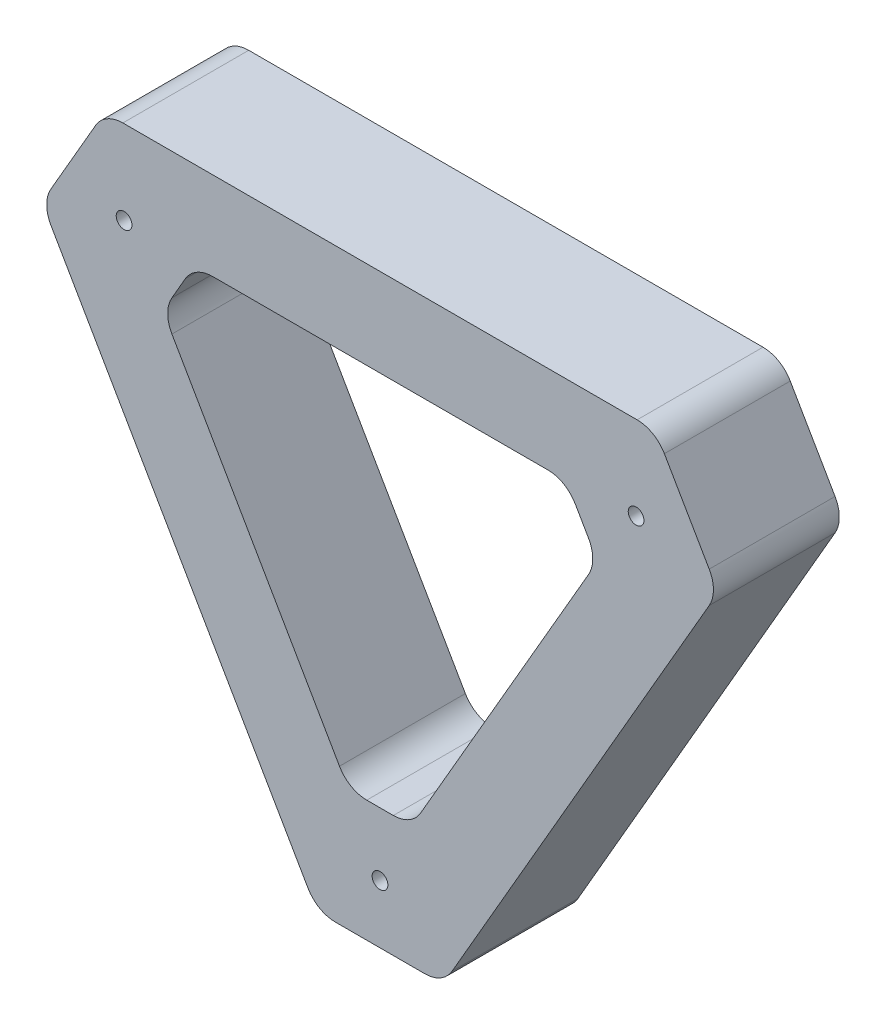
from build123d import *

# Parameters (mm, degrees)
MODEL_R                  = 1.25
RESSALTO_EXTRUS_O1_DEPTH = 20


with BuildPart() as part:
    # Model → Ressalto-extrusão1 (new body)
    with BuildSketch(Plane.XY):
        with BuildLine():
            Line((11.694931393, 184.007671687), (18.798816999, 196.310732401))
            ThreePointArc((18.798816999, 196.310732401), (20.628779754, 198.140639612), (23.128489927, 198.81054493))
            Line((23.128489927, 198.81054493), (104.854461984, 198.816198006))
            ThreePointArc((104.854461984, 198.816198006), (107.353091528, 198.147315496), (109.183125054, 196.319330074))
            Line((109.183125054, 196.319330074), (116.309159239, 183.99727285))
            ThreePointArc((116.309159239, 183.99727285), (116.980841789, 181.495674545), (116.310694096, 178.993664633))
            Line((116.310694096, 178.993664633), (75.435169171, 108.213155276))
            ThreePointArc((75.435169171, 108.213155276), (73.605079007, 106.383366964), (71.105317099, 105.713631437))
            Line((71.105317099, 105.713631437), (56.87911326, 105.713631437))
            ThreePointArc((56.87911326, 105.713631437), (54.378684602, 106.383751932), (52.548491341, 108.214488825))
            Line((52.548491341, 108.214488825), (11.694328258, 179.008341616))
            ThreePointArc((11.694328258, 179.008341616), (11.024950213, 181.508087444), (11.694931393, 184.007671687))
        make_face()
        with Locations((23.321458454, 185.48579228)):
            Circle(MODEL_R, mode=Mode.SUBTRACT)
        with Locations((63.991701896, 114.980441868)):
            Circle(MODEL_R, mode=Mode.SUBTRACT)
        with Locations((104.686697162, 185.492130263)):
            Circle(MODEL_R, mode=Mode.SUBTRACT)
        with BuildLine():
            Line((30.926807018, 178.651666079), (33.041188625, 182.313516329))
            ThreePointArc((33.041188625, 182.313516329), (34.870788611, 184.143214068), (37.370023748, 184.813328729))
            Line((37.370023748, 184.813328729), (90.685321042, 184.825950173))
            ThreePointArc((90.685321042, 184.825950173), (93.184425519, 184.157277084), (95.014821917, 182.329082369))
            Line((95.014821917, 182.329082369), (97.129519324, 178.672431029))
            ThreePointArc((97.129519324, 178.672431029), (97.801202073, 176.169904784), (97.130125767, 173.667215847))
            Line((97.130125767, 173.667215847), (70.44074248, 127.491170956))
            ThreePointArc((70.44074248, 127.491170956), (68.610777042, 125.662525758), (66.111818822, 124.993254082))
            Line((66.111818822, 124.993254082), (61.884877937, 124.993254082))
            ThreePointArc((61.884877937, 124.993254082), (59.3841246, 125.66356209), (57.553881257, 127.494760984))
            Line((57.553881257, 127.494760984), (30.925829122, 173.652985522))
            ThreePointArc((30.925829122, 173.652985522), (30.256825897, 176.152456774), (30.926807018, 178.651666079))
        make_face(mode=Mode.SUBTRACT)
    extrude(amount=RESSALTO_EXTRUS_O1_DEPTH)


solid = part.part
